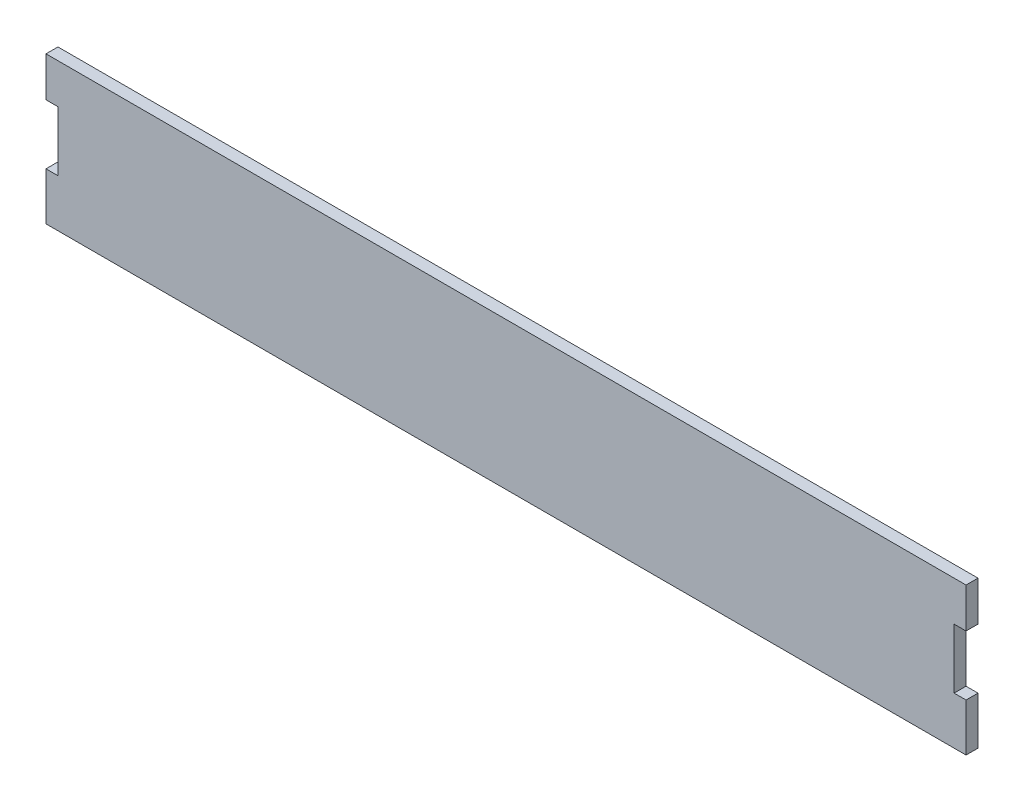
from build123d import *

# Parameters (mm, degrees)
BOSS_EXTRUDE1_DEPTH = 3


with BuildPart() as part:
    # Sketch1 → Boss-Extrude1 (new body)
    with BuildSketch(Plane.XY):
        Polygon((-113.5, 8.593370453), (-116.5, 8.593370453), (-116.5, 18.593370453), (-113.5, 18.593370453), (111.5, 18.593370453), (114.5, 18.593370453), (114.5, 8.593370453), (111.5, 8.593370453), (111.5, -6.406629547), (114.5, -6.406629547), (114.5, -18.383137088), (112.216666945, -18.383137088), (-110.239280743, -18.383137088), (-116.5, -18.383137088), (-116.5, -6.406629547), (-113.5, -6.406629547), align=None)
    extrude(amount=BOSS_EXTRUDE1_DEPTH)


solid = part.part
